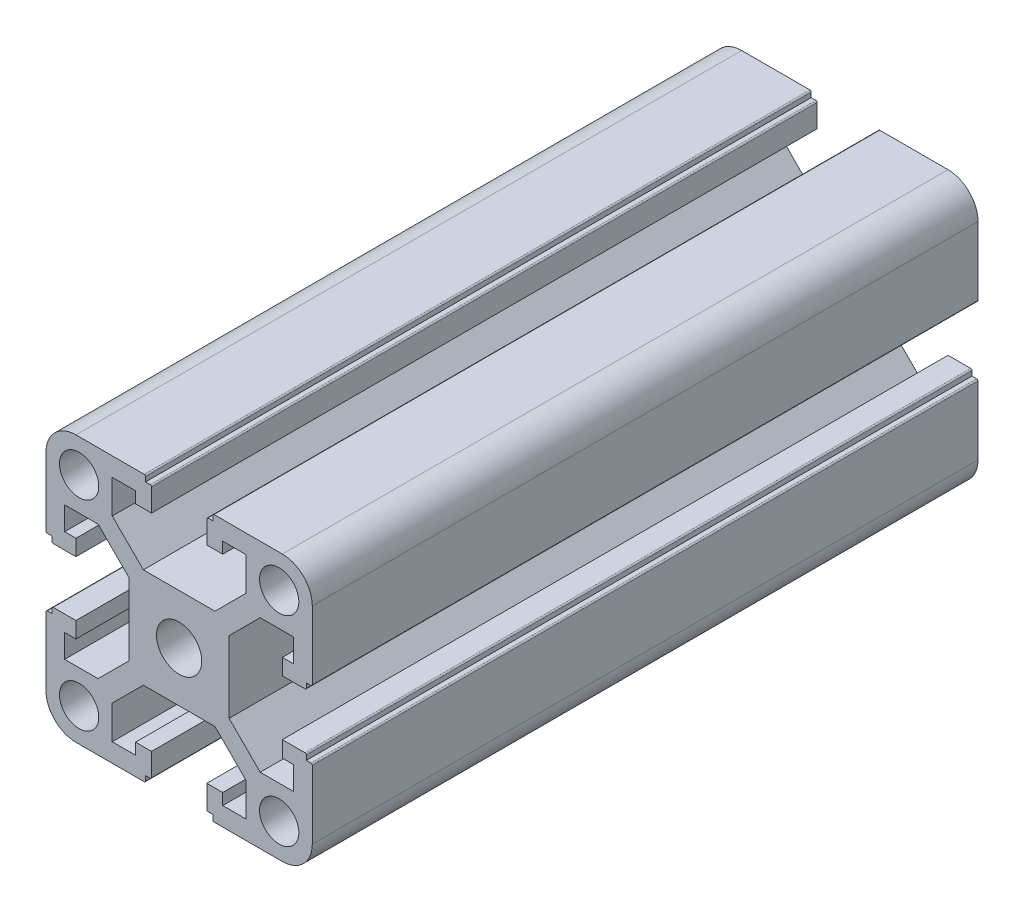
from build123d import *

# Parameters (mm, degrees)
SKETCH_1_R      = 2.95
SKETCH_1_R_2    = 3.4
EXTRUDE_1_DEPTH = 50


with BuildPart() as part:
    # 草图1 → 凸台-拉伸1 (new body, symmetric)
    with BuildSketch(Plane.XY.offset(50)):
        with BuildLine():
            Line((-1518.245004392, 3588.004280474), (-1518.245004392, 3582.975600817))
            Line((-1518.245004392, 3582.975600817), (-1522.916324736, 3578.304280474))
            Line((-1522.916324736, 3578.304280474), (-1533.673684048, 3578.304280474))
            Line((-1533.673684048, 3578.304280474), (-1538.345004392, 3582.975600817))
            Line((-1538.345004392, 3582.975600817), (-1538.345004392, 3588.004280474))
            Line((-1538.345004392, 3588.004280474), (-1534.845004392, 3588.004280474))
            Line((-1534.845004392, 3588.004280474), (-1534.845004392, 3586.304280474))
            Line((-1534.845004392, 3586.304280474), (-1532.445004392, 3586.304280474))
            Line((-1532.445004392, 3586.304280474), (-1532.445004392, 3589.704280474))
            ThreePointArc((-1532.445004392, 3589.704280474), (-1532.503583036, 3589.84570183), (-1532.645004392, 3589.904280474))
            Line((-1532.645004392, 3589.904280474), (-1533.345004392, 3589.904280474))
            Line((-1533.345004392, 3589.904280474), (-1533.345004392, 3590.604280474))
            ThreePointArc((-1533.345004392, 3590.604280474), (-1533.403583036, 3590.74570183), (-1533.545004392, 3590.804280474))
            Line((-1533.545004392, 3590.804280474), (-1543.795004392, 3590.804280474))
            ThreePointArc((-1543.795004392, 3590.804280474), (-1546.976984907, 3589.486260989), (-1548.295004392, 3586.304280474))
            Line((-1548.295004392, 3586.304280474), (-1548.295004392, 3576.054280474))
            ThreePointArc((-1548.295004392, 3576.054280474), (-1548.236425748, 3575.912859117), (-1548.095004392, 3575.854280474))
            Line((-1548.095004392, 3575.854280474), (-1547.395004392, 3575.854280474))
            Line((-1547.395004392, 3575.854280474), (-1547.395004392, 3575.154280474))
            ThreePointArc((-1547.395004392, 3575.154280474), (-1547.336425748, 3575.012859117), (-1547.195004392, 3574.954280474))
            Line((-1547.195004392, 3574.954280474), (-1543.795004392, 3574.954280474))
            Line((-1543.795004392, 3574.954280474), (-1543.795004392, 3577.354280474))
            Line((-1543.795004392, 3577.354280474), (-1545.495004392, 3577.354280474))
            Line((-1545.495004392, 3577.354280474), (-1545.495004392, 3580.854280474))
            Line((-1545.495004392, 3580.854280474), (-1540.466324736, 3580.854280474))
            Line((-1540.466324736, 3580.854280474), (-1535.795004392, 3576.18296013))
            Line((-1535.795004392, 3576.18296013), (-1535.795004392, 3565.425600817))
            Line((-1535.795004392, 3565.425600817), (-1540.466324736, 3560.754280474))
            Line((-1540.466324736, 3560.754280474), (-1545.495004392, 3560.754280474))
            Line((-1545.495004392, 3560.754280474), (-1545.495004392, 3564.254280474))
            Line((-1545.495004392, 3564.254280474), (-1543.795004392, 3564.254280474))
            Line((-1543.795004392, 3564.254280474), (-1543.795004392, 3566.654280474))
            Line((-1543.795004392, 3566.654280474), (-1547.195004392, 3566.654280474))
            ThreePointArc((-1547.195004392, 3566.654280474), (-1547.336425748, 3566.59570183), (-1547.395004392, 3566.454280474))
            Line((-1547.395004392, 3566.454280474), (-1547.395004392, 3565.754280474))
            Line((-1547.395004392, 3565.754280474), (-1548.095004392, 3565.754280474))
            ThreePointArc((-1548.095004392, 3565.754280474), (-1548.236425748, 3565.69570183), (-1548.295004392, 3565.554280474))
            Line((-1548.295004392, 3565.554280474), (-1548.295004392, 3555.304280474))
            ThreePointArc((-1548.295004392, 3555.304280474), (-1546.976984907, 3552.122299958), (-1543.795004392, 3550.804280474))
            Line((-1543.795004392, 3550.804280474), (-1533.545004392, 3550.804280474))
            ThreePointArc((-1533.545004392, 3550.804280474), (-1533.403583036, 3550.862859117), (-1533.345004392, 3551.004280474))
            Line((-1533.345004392, 3551.004280474), (-1533.345004392, 3551.704280474))
            Line((-1533.345004392, 3551.704280474), (-1532.645004392, 3551.704280474))
            ThreePointArc((-1532.645004392, 3551.704280474), (-1532.503583036, 3551.762859117), (-1532.445004392, 3551.904280474))
            Line((-1532.445004392, 3551.904280474), (-1532.445004392, 3555.304280474))
            Line((-1532.445004392, 3555.304280474), (-1534.845004392, 3555.304280474))
            Line((-1534.845004392, 3555.304280474), (-1534.845004392, 3553.604280474))
            Line((-1534.845004392, 3553.604280474), (-1538.345004392, 3553.604280474))
            Line((-1538.345004392, 3553.604280474), (-1538.345004392, 3558.63296013))
            Line((-1538.345004392, 3558.63296013), (-1533.673684048, 3563.304280474))
            Line((-1533.673684048, 3563.304280474), (-1522.916324736, 3563.304280474))
            Line((-1522.916324736, 3563.304280474), (-1518.245004392, 3558.63296013))
            Line((-1518.245004392, 3558.63296013), (-1518.245004392, 3553.604280474))
            Line((-1518.245004392, 3553.604280474), (-1521.745004392, 3553.604280474))
            Line((-1521.745004392, 3553.604280474), (-1521.745004392, 3555.304280474))
            Line((-1521.745004392, 3555.304280474), (-1524.145004392, 3555.304280474))
            Line((-1524.145004392, 3555.304280474), (-1524.145004392, 3551.904280474))
            ThreePointArc((-1524.145004392, 3551.904280474), (-1524.086425748, 3551.762859117), (-1523.945004392, 3551.704280474))
            Line((-1523.945004392, 3551.704280474), (-1523.245004392, 3551.704280474))
            Line((-1523.245004392, 3551.704280474), (-1523.245004392, 3551.004280474))
            ThreePointArc((-1523.245004392, 3551.004280474), (-1523.186425748, 3550.862859117), (-1523.045004392, 3550.804280474))
            Line((-1523.045004392, 3550.804280474), (-1512.795004392, 3550.804280474))
            ThreePointArc((-1512.795004392, 3550.804280474), (-1509.613023877, 3552.122299958), (-1508.295004392, 3555.304280474))
            Line((-1508.295004392, 3555.304280474), (-1508.295004392, 3565.554280474))
            ThreePointArc((-1508.295004392, 3565.554280474), (-1508.353583036, 3565.69570183), (-1508.495004392, 3565.754280474))
            Line((-1508.495004392, 3565.754280474), (-1509.195004392, 3565.754280474))
            Line((-1509.195004392, 3565.754280474), (-1509.195004392, 3566.454280474))
            ThreePointArc((-1509.195004392, 3566.454280474), (-1509.253583036, 3566.59570183), (-1509.395004392, 3566.654280474))
            Line((-1509.395004392, 3566.654280474), (-1512.795004392, 3566.654280474))
            Line((-1512.795004392, 3566.654280474), (-1512.795004392, 3564.254280474))
            Line((-1512.795004392, 3564.254280474), (-1511.095004392, 3564.254280474))
            Line((-1511.095004392, 3564.254280474), (-1511.095004392, 3560.754280474))
            Line((-1511.095004392, 3560.754280474), (-1516.123684048, 3560.754280474))
            Line((-1516.123684048, 3560.754280474), (-1520.795004392, 3565.425600817))
            Line((-1520.795004392, 3565.425600817), (-1520.795004392, 3576.18296013))
            Line((-1520.795004392, 3576.18296013), (-1516.123684048, 3580.854280474))
            Line((-1516.123684048, 3580.854280474), (-1511.095004392, 3580.854280474))
            Line((-1511.095004392, 3580.854280474), (-1511.095004392, 3577.354280474))
            Line((-1511.095004392, 3577.354280474), (-1512.795004392, 3577.354280474))
            Line((-1512.795004392, 3577.354280474), (-1512.795004392, 3574.954280474))
            Line((-1512.795004392, 3574.954280474), (-1509.395004392, 3574.954280474))
            ThreePointArc((-1509.395004392, 3574.954280474), (-1509.253583036, 3575.012859117), (-1509.195004392, 3575.154280474))
            Line((-1509.195004392, 3575.154280474), (-1509.195004392, 3575.854280474))
            Line((-1509.195004392, 3575.854280474), (-1508.495004392, 3575.854280474))
            ThreePointArc((-1508.495004392, 3575.854280474), (-1508.353583036, 3575.912859117), (-1508.295004392, 3576.054280474))
            Line((-1508.295004392, 3576.054280474), (-1508.295004392, 3586.304280474))
            ThreePointArc((-1508.295004392, 3586.304280474), (-1509.613023877, 3589.486260989), (-1512.795004392, 3590.804280474))
            Line((-1512.795004392, 3590.804280474), (-1523.045004392, 3590.804280474))
            ThreePointArc((-1523.045004392, 3590.804280474), (-1523.186425748, 3590.74570183), (-1523.245004392, 3590.604280474))
            Line((-1523.245004392, 3590.604280474), (-1523.245004392, 3589.904280474))
            Line((-1523.245004392, 3589.904280474), (-1523.945004392, 3589.904280474))
            ThreePointArc((-1523.945004392, 3589.904280474), (-1524.086425748, 3589.84570183), (-1524.145004392, 3589.704280474))
            Line((-1524.145004392, 3589.704280474), (-1524.145004392, 3586.304280474))
            Line((-1524.145004392, 3586.304280474), (-1521.745004392, 3586.304280474))
            Line((-1521.745004392, 3586.304280474), (-1521.745004392, 3588.004280474))
            Line((-1521.745004392, 3588.004280474), (-1518.245004392, 3588.004280474))
        make_face()
        with Locations((-1513.270004392, 3555.779280474)):
            Circle(SKETCH_1_R, mode=Mode.SUBTRACT)
        with Locations((-1528.295004392, 3570.804280474)):
            Circle(SKETCH_1_R_2, mode=Mode.SUBTRACT)
        with Locations((-1513.270004392, 3585.829280474)):
            Circle(SKETCH_1_R, mode=Mode.SUBTRACT)
        with Locations((-1543.320004392, 3585.829280474)):
            Circle(SKETCH_1_R, mode=Mode.SUBTRACT)
        with Locations((-1543.320004392, 3555.779280474)):
            Circle(SKETCH_1_R, mode=Mode.SUBTRACT)
    extrude(amount=EXTRUDE_1_DEPTH, both=True)


solid = part.part
